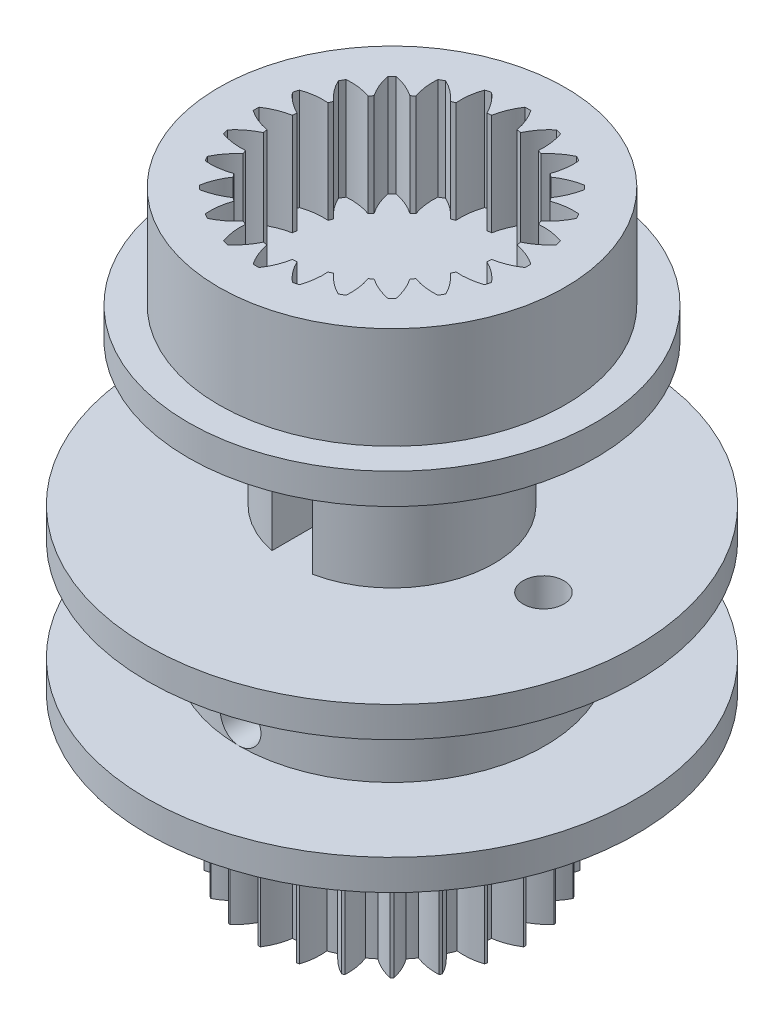
from build123d import *

# Parameters (mm, degrees)
BOSS_EXTRUDE1_DEPTH = 7.5
SKETCH2_R           = 12
BOSS_EXTRUDE2_DEPTH = 1.5
SKETCH3_R           = 7.5
BOSS_EXTRUDE3_DEPTH = 5
SKETCH4_R           = 12
BOSS_EXTRUDE4_DEPTH = 1.5
SKETCH6_R           = 5
BOSS_EXTRUDE5_DEPTH = 7
SKETCH9_R           = 10
BOSS_EXTRUDE6_DEPTH = 1.5
SKETCH11_R          = 8.5
BOSS_EXTRUDE7_DEPTH = 5
SKETCH7_R           = 1
SKETCH7_W           = 2
SKETCH7_H           = 7
CUT_EXTRUDE1_DEPTH  = 25.02148298
SKETCH13_R          = 1
CUT_EXTRUDE2_DEPTH  = 4


with BuildPart() as part:
    # Sketch1 → Boss-Extrude1 (new body)
    with BuildSketch(Plane(origin=(0, 0, 0), x_dir=(1, 0, 0), z_dir=(0, 1, 0))):
        with BuildLine():
            ThreePointArc((17.643526795, -5.495767992), (17.367772644, -6.046845758), (17.21467944, -6.643745688))
            ThreePointArc((17.21467944, -6.643745688), (16.99967637, -6.667680728), (16.785804508, -6.700208145))
            ThreePointArc((16.785804508, -6.700208145), (16.483438759, -6.163270523), (16.074451282, -5.702340703))
            ThreePointArc((16.074451282, -5.702340703), (16.01546472, -5.717851037), (15.956625692, -5.733911974))
            ThreePointArc((15.956625692, -5.733911974), (15.832897056, -6.337582647), (15.839509448, -6.953767142))
            ThreePointArc((15.839509448, -6.953767142), (15.638027273, -7.032533504), (15.439861633, -7.119306687))
            ThreePointArc((15.439861633, -7.119306687), (15.008829064, -6.678922785), (14.494480081, -6.339552516))
            ThreePointArc((14.494480081, -6.339552516), (14.441517808, -6.369801195), (14.388840548, -6.400543529))
            ThreePointArc((14.388840548, -6.400543529), (14.42556933, -7.01566795), (14.591436692, -7.609145055))
            ThreePointArc((14.591436692, -7.609145055), (14.417206092, -7.737374942), (14.248251334, -7.872480442))
            ThreePointArc((14.248251334, -7.872480442), (13.717926103, -7.558661696), (13.133267648, -7.363978501))
            ThreePointArc((13.133267648, -7.363978501), (13.089938954, -7.406904126), (13.047013329, -7.450232819))
            ThreePointArc((13.047013329, -7.450232819), (13.241696524, -8.034891275), (13.555515271, -8.565216505))
            ThreePointArc((13.555515271, -8.565216505), (13.420409771, -8.734171263), (13.292179883, -8.908401864))
            ThreePointArc((13.292179883, -8.908401864), (12.698702778, -8.742534502), (12.083578358, -8.705805719))
            ThreePointArc((12.083578358, -8.705805719), (12.052836023, -8.75848298), (12.022587345, -8.811445253))
            ThreePointArc((12.022587345, -8.811445253), (12.361957614, -9.325794236), (12.802341515, -9.756826804))
            ThreePointArc((12.802341515, -9.756826804), (12.715568333, -9.954992445), (12.63680197, -10.156474619))
            ThreePointArc((12.63680197, -10.156474619), (12.020617475, -10.149862228), (11.416946803, -10.273590863))
            ThreePointArc((11.416946803, -10.273590863), (11.400885866, -10.332429891), (11.385375531, -10.391416453))
            ThreePointArc((11.385375531, -10.391416453), (11.846305351, -10.80040393), (12.383242973, -11.102769679))
            ThreePointArc((12.383242973, -11.102769679), (12.350715557, -11.316641542), (12.326780517, -11.531644612))
            ThreePointArc((12.326780517, -11.531644612), (11.729880587, -11.684737815), (11.178802821, -11.960491966))
            ThreePointArc((11.178802821, -11.960491966), (11.178517808, -12.02148298), (11.178802821, -12.082473993))
            ThreePointArc((11.178802821, -12.082473993), (11.729880587, -12.358228144), (12.326780517, -12.511321347))
            ThreePointArc((12.326780517, -12.511321347), (12.350715557, -12.726324418), (12.383242973, -12.94019628))
            ThreePointArc((12.383242973, -12.94019628), (11.846305351, -13.242562029), (11.385375531, -13.651549506))
            ThreePointArc((11.385375531, -13.651549506), (11.400885866, -13.710536068), (11.416946803, -13.769375096))
            ThreePointArc((11.416946803, -13.769375096), (12.020617475, -13.893103732), (12.63680197, -13.88649134))
            ThreePointArc((12.63680197, -13.88649134), (12.715568333, -14.087973515), (12.802341515, -14.286139155))
            ThreePointArc((12.802341515, -14.286139155), (12.361957614, -14.717171723), (12.022587345, -15.231520706))
            ThreePointArc((12.022587345, -15.231520706), (12.052836023, -15.28448298), (12.083578358, -15.33716024))
            ThreePointArc((12.083578358, -15.33716024), (12.698702778, -15.300431458), (13.292179883, -15.134564096))
            ThreePointArc((13.292179883, -15.134564096), (13.420409771, -15.308794696), (13.555515271, -15.477749454))
            ThreePointArc((13.555515271, -15.477749454), (13.241696524, -16.008074685), (13.047013329, -16.59273314))
            ThreePointArc((13.047013329, -16.59273314), (13.089938954, -16.636061834), (13.133267648, -16.678987459))
            ThreePointArc((13.133267648, -16.678987459), (13.717926103, -16.484304264), (14.248251334, -16.170485517))
            ThreePointArc((14.248251334, -16.170485517), (14.417206092, -16.305591017), (14.591436692, -16.433820905))
            ThreePointArc((14.591436692, -16.433820905), (14.42556933, -17.02729801), (14.388840548, -17.64242243))
            ThreePointArc((14.388840548, -17.64242243), (14.441517808, -17.673164765), (14.494480081, -17.703413443))
            ThreePointArc((14.494480081, -17.703413443), (15.008829064, -17.364043174), (15.439861633, -16.923659273))
            ThreePointArc((15.439861633, -16.923659273), (15.638027273, -17.010432455), (15.839509448, -17.089198818))
            ThreePointArc((15.839509448, -17.089198818), (15.832897056, -17.705383313), (15.956625692, -18.309053985))
            ThreePointArc((15.956625692, -18.309053985), (16.01546472, -18.325114922), (16.074451282, -18.340625257))
            ThreePointArc((16.074451282, -18.340625257), (16.483438759, -17.879695437), (16.785804508, -17.342757815))
            ThreePointArc((16.785804508, -17.342757815), (16.99967637, -17.375285231), (17.21467944, -17.399220271))
            ThreePointArc((17.21467944, -17.399220271), (17.367772644, -17.996120201), (17.643526795, -18.547197967))
            ThreePointArc((17.643526795, -18.547197967), (17.704517808, -18.54748298), (17.765508822, -18.547197967))
            ThreePointArc((17.765508822, -18.547197967), (18.041262973, -17.996120201), (18.194356176, -17.399220271))
            ThreePointArc((18.194356176, -17.399220271), (18.409359246, -17.375285231), (18.623231109, -17.342757815))
            ThreePointArc((18.623231109, -17.342757815), (18.925596857, -17.879695437), (19.334584335, -18.340625257))
            ThreePointArc((19.334584335, -18.340625257), (19.393570897, -18.325114922), (19.452409925, -18.309053985))
            ThreePointArc((19.452409925, -18.309053985), (19.57613856, -17.705383313), (19.569526169, -17.089198818))
            ThreePointArc((19.569526169, -17.089198818), (19.771008343, -17.010432455), (19.969173984, -16.923659273))
            ThreePointArc((19.969173984, -16.923659273), (20.400206552, -17.364043174), (20.914555535, -17.703413443))
            ThreePointArc((20.914555535, -17.703413443), (20.967517808, -17.673164765), (21.020195069, -17.64242243))
            ThreePointArc((21.020195069, -17.64242243), (20.983466286, -17.02729801), (20.817598924, -16.433820905))
            ThreePointArc((20.817598924, -16.433820905), (20.991829525, -16.305591017), (21.160784283, -16.170485517))
            ThreePointArc((21.160784283, -16.170485517), (21.691109513, -16.484304264), (22.275767969, -16.678987459))
            ThreePointArc((22.275767969, -16.678987459), (22.319096662, -16.636061834), (22.362022287, -16.59273314))
            ThreePointArc((22.362022287, -16.59273314), (22.167339092, -16.008074685), (21.853520346, -15.477749454))
            ThreePointArc((21.853520346, -15.477749454), (21.988625846, -15.308794696), (22.116855733, -15.134564096))
            ThreePointArc((22.116855733, -15.134564096), (22.710332838, -15.300431458), (23.325457258, -15.33716024))
            ThreePointArc((23.325457258, -15.33716024), (23.356199593, -15.28448298), (23.386448272, -15.231520706))
            ThreePointArc((23.386448272, -15.231520706), (23.047078003, -14.717171723), (22.606694101, -14.286139155))
            ThreePointArc((22.606694101, -14.286139155), (22.693467284, -14.087973515), (22.772233646, -13.88649134))
            ThreePointArc((22.772233646, -13.88649134), (23.388418141, -13.893103732), (23.992088814, -13.769375096))
            ThreePointArc((23.992088814, -13.769375096), (24.008149751, -13.710536068), (24.023660085, -13.651549506))
            ThreePointArc((24.023660085, -13.651549506), (23.562730265, -13.242562029), (23.025792643, -12.94019628))
            ThreePointArc((23.025792643, -12.94019628), (23.05832006, -12.726324418), (23.082255099, -12.511321347))
            ThreePointArc((23.082255099, -12.511321347), (23.67915503, -12.358228144), (24.230232796, -12.082473993))
            ThreePointArc((24.230232796, -12.082473993), (24.230517808, -12.02148298), (24.230232796, -11.960491966))
            ThreePointArc((24.230232796, -11.960491966), (23.67915503, -11.684737815), (23.082255099, -11.531644612))
            ThreePointArc((23.082255099, -11.531644612), (23.05832006, -11.316641542), (23.025792643, -11.102769679))
            ThreePointArc((23.025792643, -11.102769679), (23.562730265, -10.80040393), (24.023660085, -10.391416453))
            ThreePointArc((24.023660085, -10.391416453), (24.008149751, -10.332429891), (23.992088814, -10.273590863))
            ThreePointArc((23.992088814, -10.273590863), (23.388418141, -10.149862228), (22.772233646, -10.156474619))
            ThreePointArc((22.772233646, -10.156474619), (22.693467284, -9.954992445), (22.606694101, -9.756826804))
            ThreePointArc((22.606694101, -9.756826804), (23.047078003, -9.325794236), (23.386448272, -8.811445253))
            ThreePointArc((23.386448272, -8.811445253), (23.356199593, -8.75848298), (23.325457258, -8.705805719))
            ThreePointArc((23.325457258, -8.705805719), (22.710332838, -8.742534502), (22.116855733, -8.908401864))
            ThreePointArc((22.116855733, -8.908401864), (21.988625846, -8.734171263), (21.853520346, -8.565216505))
            ThreePointArc((21.853520346, -8.565216505), (22.167339092, -8.034891275), (22.362022287, -7.450232819))
            ThreePointArc((22.362022287, -7.450232819), (22.319096662, -7.406904126), (22.275767969, -7.363978501))
            ThreePointArc((22.275767969, -7.363978501), (21.691109513, -7.558661696), (21.160784283, -7.872480442))
            ThreePointArc((21.160784283, -7.872480442), (20.991829525, -7.737374942), (20.817598924, -7.609145055))
            ThreePointArc((20.817598924, -7.609145055), (20.983466286, -7.01566795), (21.020195069, -6.400543529))
            ThreePointArc((21.020195069, -6.400543529), (20.967517808, -6.369801195), (20.914555535, -6.339552516))
            ThreePointArc((20.914555535, -6.339552516), (20.400206552, -6.678922785), (19.969173984, -7.119306687))
            ThreePointArc((19.969173984, -7.119306687), (19.771008343, -7.032533504), (19.569526169, -6.953767142))
            ThreePointArc((19.569526169, -6.953767142), (19.57613856, -6.337582647), (19.452409925, -5.733911974))
            ThreePointArc((19.452409925, -5.733911974), (19.393570897, -5.717851037), (19.334584335, -5.702340703))
            ThreePointArc((19.334584335, -5.702340703), (18.925596857, -6.163270523), (18.623231109, -6.700208145))
            ThreePointArc((18.623231109, -6.700208145), (18.409359246, -6.667680728), (18.194356176, -6.643745688))
            ThreePointArc((18.194356176, -6.643745688), (18.041262973, -6.046845758), (17.765508822, -5.495767992))
            ThreePointArc((17.765508822, -5.495767992), (17.704517808, -5.49548298), (17.643526795, -5.495767992))
        make_face()
    extrude(amount=BOSS_EXTRUDE1_DEPTH)

    # Sketch2 → Boss-Extrude2 (add)
    with BuildSketch(Plane(origin=(0, 7.5, 0), x_dir=(1, 0, 0), z_dir=(0, 1, 0))):
        with Locations((17.704517808, -12.02148298)):
            Circle(SKETCH2_R)
    extrude(amount=BOSS_EXTRUDE2_DEPTH)

    # Sketch3 → Boss-Extrude3 (add)
    with BuildSketch(Plane(origin=(0, 9, 0), x_dir=(1, 0, 0), z_dir=(0, 1, 0))):
        with Locations((17.704517808, -12.02148298)):
            Circle(SKETCH3_R)
    extrude(amount=BOSS_EXTRUDE3_DEPTH)

    # Sketch4 → Boss-Extrude4 (add)
    with BuildSketch(Plane(origin=(0, 14, 0), x_dir=(1, 0, 0), z_dir=(0, 1, 0))):
        with Locations((17.704517808, -12.02148298)):
            Circle(SKETCH4_R)
    extrude(amount=BOSS_EXTRUDE4_DEPTH)

    # Sketch6 → Boss-Extrude5 (add)
    with BuildSketch(Plane(origin=(0, 15.5, 0), x_dir=(1, 0, 0), z_dir=(0, 1, 0))):
        with Locations((17.704517808, -12.02148298)):
            Circle(SKETCH6_R)
    extrude(amount=BOSS_EXTRUDE5_DEPTH)

    # Sketch9 → Boss-Extrude6 (add)
    with BuildSketch(Plane(origin=(0, 22.5, 0), x_dir=(1, 0, 0), z_dir=(0, 1, 0))):
        with Locations((17.704517808, -12.02148298)):
            Circle(SKETCH9_R)
    extrude(amount=BOSS_EXTRUDE6_DEPTH)

    # Sketch11 → Boss-Extrude7 (add)
    with BuildSketch(Plane(origin=(0, 24, 0), x_dir=(1, 0, 0), z_dir=(0, 1, 0))):
        with Locations((17.704517808, -12.02148298)):
            Circle(SKETCH11_R)
        with BuildLine():
            ThreePointArc((17.847000215, -5.347003617), (17.704517808, -5.34548298), (17.562035401, -5.347003617))
            ThreePointArc((17.562035401, -5.347003617), (17.263554819, -5.901817538), (17.085431236, -6.506119726))
            ThreePointArc((17.085431236, -6.506119726), (16.980097441, -6.518963999), (16.875028466, -6.533819777))
            ThreePointArc((16.875028466, -6.533819777), (16.546569382, -5.996210462), (16.11466287, -5.537553826))
            ThreePointArc((16.11466287, -5.537553826), (15.976641863, -5.572962163), (15.839407996, -5.611308147))
            ThreePointArc((15.839407996, -5.611308147), (15.694694302, -6.224469701), (15.679045049, -6.854282567))
            ThreePointArc((15.679045049, -6.854282567), (15.580624759, -6.893951574), (15.48298088, -6.935495005))
            ThreePointArc((15.48298088, -6.935495005), (15.026570239, -6.50121575), (14.490671511, -6.169973091))
            ThreePointArc((14.490671511, -6.169973091), (14.366517808, -6.239897384), (14.243884743, -6.312455498))
            ThreePointArc((14.243884743, -6.312455498), (14.262799936, -6.94217874), (14.410691483, -7.554581577))
            ThreePointArc((14.410691483, -7.554581577), (14.325891877, -7.618371941), (14.242327365, -7.683771909))
            ThreePointArc((14.242327365, -7.683771909), (13.689068796, -7.382418127), (13.085698466, -7.201163085))
            ThreePointArc((13.085698466, -7.201163085), (12.983872937, -7.300838109), (12.884197914, -7.402663638))
            ThreePointArc((12.884197914, -7.402663638), (13.065452956, -8.006033968), (13.366806738, -8.559292536))
            ThreePointArc((13.366806738, -8.559292536), (13.30140677, -8.642857049), (13.237616406, -8.727656654))
            ThreePointArc((13.237616406, -8.727656654), (12.625213568, -8.579765108), (11.995490327, -8.560849914))
            ThreePointArc((11.995490327, -8.560849914), (11.922932213, -8.68348298), (11.85300792, -8.807636682))
            ThreePointArc((11.85300792, -8.807636682), (12.184250578, -9.34353541), (12.618529834, -9.799946052))
            ThreePointArc((12.618529834, -9.799946052), (12.576986403, -9.89758993), (12.537317396, -9.99601022))
            ThreePointArc((12.537317396, -9.99601022), (11.90750453, -10.011659474), (11.294342975, -10.156373168))
            ThreePointArc((11.294342975, -10.156373168), (11.255996992, -10.293607035), (11.220588654, -10.431628041))
            ThreePointArc((11.220588654, -10.431628041), (11.67924529, -10.863534554), (12.216854605, -11.191993638))
            ThreePointArc((12.216854605, -11.191993638), (12.201998828, -11.297062613), (12.189154555, -11.402396407))
            ThreePointArc((12.189154555, -11.402396407), (11.584852367, -11.58051999), (11.030038445, -11.879000573))
            ThreePointArc((11.030038445, -11.879000573), (11.028517808, -12.02148298), (11.030038445, -12.163965387))
            ThreePointArc((11.030038445, -12.163965387), (11.584852367, -12.462445969), (12.189154555, -12.640569552))
            ThreePointArc((12.189154555, -12.640569552), (12.201998828, -12.745903347), (12.216854605, -12.850972321))
            ThreePointArc((12.216854605, -12.850972321), (11.67924529, -13.179431406), (11.220588654, -13.611337918))
            ThreePointArc((11.220588654, -13.611337918), (11.255996992, -13.749358925), (11.294342975, -13.886592792))
            ThreePointArc((11.294342975, -13.886592792), (11.90750453, -14.031306486), (12.537317396, -14.046955739))
            ThreePointArc((12.537317396, -14.046955739), (12.576986403, -14.145376029), (12.618529834, -14.243019908))
            ThreePointArc((12.618529834, -14.243019908), (12.184250578, -14.699430549), (11.85300792, -15.235329277))
            ThreePointArc((11.85300792, -15.235329277), (11.922932213, -15.35948298), (11.995490327, -15.482116045))
            ThreePointArc((11.995490327, -15.482116045), (12.625213568, -15.463200852), (13.237616406, -15.315309305))
            ThreePointArc((13.237616406, -15.315309305), (13.30140677, -15.400108911), (13.366806738, -15.483673423))
            ThreePointArc((13.366806738, -15.483673423), (13.065452956, -16.036931992), (12.884197914, -16.640302322))
            ThreePointArc((12.884197914, -16.640302322), (12.983872937, -16.742127851), (13.085698466, -16.841802874))
            ThreePointArc((13.085698466, -16.841802874), (13.689068796, -16.660547832), (14.242327365, -16.35919405))
            ThreePointArc((14.242327365, -16.35919405), (14.325891877, -16.424594018), (14.410691483, -16.488384382))
            ThreePointArc((14.410691483, -16.488384382), (14.262799936, -17.10078722), (14.243884743, -17.730510461))
            ThreePointArc((14.243884743, -17.730510461), (14.366517808, -17.803068575), (14.490671511, -17.872992868))
            ThreePointArc((14.490671511, -17.872992868), (15.026570239, -17.54175021), (15.48298088, -17.107470954))
            ThreePointArc((15.48298088, -17.107470954), (15.580624759, -17.149014385), (15.679045049, -17.188683392))
            ThreePointArc((15.679045049, -17.188683392), (15.694694302, -17.818496258), (15.839407996, -18.431657813))
            ThreePointArc((15.839407996, -18.431657813), (15.976641863, -18.470003796), (16.11466287, -18.505412134))
            ThreePointArc((16.11466287, -18.505412134), (16.546569382, -18.046755498), (16.875028466, -17.509146183))
            ThreePointArc((16.875028466, -17.509146183), (16.980097441, -17.52400196), (17.085431236, -17.536846233))
            ThreePointArc((17.085431236, -17.536846233), (17.263554819, -18.141148421), (17.562035401, -18.695962342))
            ThreePointArc((17.562035401, -18.695962342), (17.704517808, -18.69748298), (17.847000215, -18.695962342))
            ThreePointArc((17.847000215, -18.695962342), (18.145480798, -18.141148421), (18.323604381, -17.536846233))
            ThreePointArc((18.323604381, -17.536846233), (18.428938175, -17.52400196), (18.53400715, -17.509146183))
            ThreePointArc((18.53400715, -17.509146183), (18.862466234, -18.046755498), (19.294372747, -18.505412134))
            ThreePointArc((19.294372747, -18.505412134), (19.432393753, -18.470003796), (19.56962762, -18.431657813))
            ThreePointArc((19.56962762, -18.431657813), (19.714341314, -17.818496258), (19.729990568, -17.188683392))
            ThreePointArc((19.729990568, -17.188683392), (19.828410858, -17.149014385), (19.926054736, -17.107470954))
            ThreePointArc((19.926054736, -17.107470954), (20.382465378, -17.54175021), (20.918364105, -17.872992868))
            ThreePointArc((20.918364105, -17.872992868), (21.042517808, -17.803068575), (21.165150874, -17.730510461))
            ThreePointArc((21.165150874, -17.730510461), (21.14623568, -17.10078722), (20.998344134, -16.488384382))
            ThreePointArc((20.998344134, -16.488384382), (21.083143739, -16.424594018), (21.166708252, -16.35919405))
            ThreePointArc((21.166708252, -16.35919405), (21.71996682, -16.660547832), (22.32333715, -16.841802874))
            ThreePointArc((22.32333715, -16.841802874), (22.425162679, -16.742127851), (22.524837703, -16.640302322))
            ThreePointArc((22.524837703, -16.640302322), (22.343582661, -16.036931992), (22.042228879, -15.483673423))
            ThreePointArc((22.042228879, -15.483673423), (22.107628847, -15.400108911), (22.171419211, -15.315309305))
            ThreePointArc((22.171419211, -15.315309305), (22.783822048, -15.463200852), (23.41354529, -15.482116045))
            ThreePointArc((23.41354529, -15.482116045), (23.486103404, -15.35948298), (23.556027697, -15.235329277))
            ThreePointArc((23.556027697, -15.235329277), (23.224785038, -14.699430549), (22.790505783, -14.243019908))
            ThreePointArc((22.790505783, -14.243019908), (22.832049214, -14.145376029), (22.87171822, -14.046955739))
            ThreePointArc((22.87171822, -14.046955739), (23.501531086, -14.031306486), (24.114692641, -13.886592792))
            ThreePointArc((24.114692641, -13.886592792), (24.153038625, -13.749358925), (24.188446962, -13.611337918))
            ThreePointArc((24.188446962, -13.611337918), (23.729790326, -13.179431406), (23.192181011, -12.850972321))
            ThreePointArc((23.192181011, -12.850972321), (23.207036789, -12.745903347), (23.219881062, -12.640569552))
            ThreePointArc((23.219881062, -12.640569552), (23.82418325, -12.462445969), (24.378997171, -12.163965387))
            ThreePointArc((24.378997171, -12.163965387), (24.380517808, -12.02148298), (24.378997171, -11.879000573))
            ThreePointArc((24.378997171, -11.879000573), (23.82418325, -11.58051999), (23.219881062, -11.402396407))
            ThreePointArc((23.219881062, -11.402396407), (23.207036789, -11.297062613), (23.192181011, -11.191993638))
            ThreePointArc((23.192181011, -11.191993638), (23.729790326, -10.863534554), (24.188446962, -10.431628041))
            ThreePointArc((24.188446962, -10.431628041), (24.153038625, -10.293607035), (24.114692641, -10.156373168))
            ThreePointArc((24.114692641, -10.156373168), (23.501531086, -10.011659474), (22.87171822, -9.99601022))
            ThreePointArc((22.87171822, -9.99601022), (22.832049214, -9.89758993), (22.790505783, -9.799946052))
            ThreePointArc((22.790505783, -9.799946052), (23.224785038, -9.34353541), (23.556027697, -8.807636682))
            ThreePointArc((23.556027697, -8.807636682), (23.486103404, -8.68348298), (23.41354529, -8.560849914))
            ThreePointArc((23.41354529, -8.560849914), (22.783822048, -8.579765108), (22.171419211, -8.727656654))
            ThreePointArc((22.171419211, -8.727656654), (22.107628847, -8.642857049), (22.042228879, -8.559292536))
            ThreePointArc((22.042228879, -8.559292536), (22.343582661, -8.006033968), (22.524837703, -7.402663638))
            ThreePointArc((22.524837703, -7.402663638), (22.425162679, -7.300838109), (22.32333715, -7.201163085))
            ThreePointArc((22.32333715, -7.201163085), (21.71996682, -7.382418127), (21.166708252, -7.683771909))
            ThreePointArc((21.166708252, -7.683771909), (21.083143739, -7.618371941), (20.998344134, -7.554581577))
            ThreePointArc((20.998344134, -7.554581577), (21.14623568, -6.94217874), (21.165150874, -6.312455498))
            ThreePointArc((21.165150874, -6.312455498), (21.042517808, -6.239897384), (20.918364105, -6.169973091))
            ThreePointArc((20.918364105, -6.169973091), (20.382465378, -6.50121575), (19.926054736, -6.935495005))
            ThreePointArc((19.926054736, -6.935495005), (19.828410858, -6.893951574), (19.729990568, -6.854282567))
            ThreePointArc((19.729990568, -6.854282567), (19.714341314, -6.224469701), (19.56962762, -5.611308147))
            ThreePointArc((19.56962762, -5.611308147), (19.432393753, -5.572962163), (19.294372747, -5.537553826))
            ThreePointArc((19.294372747, -5.537553826), (18.862466234, -5.996210462), (18.53400715, -6.533819777))
            ThreePointArc((18.53400715, -6.533819777), (18.428938175, -6.518963999), (18.323604381, -6.506119726))
            ThreePointArc((18.323604381, -6.506119726), (18.145480798, -5.901817538), (17.847000215, -5.347003617))
        make_face(mode=Mode.SUBTRACT)
    extrude(amount=BOSS_EXTRUDE7_DEPTH)

    # Sketch7 → Cut-Extrude1 (cut, through all)
    with BuildSketch(Plane.XY):
        with Locations((17.704517808, 10)):
            Circle(SKETCH7_R)
        with Locations((17.704517808, 19)):
            Rectangle(SKETCH7_W, SKETCH7_H)
    extrude(amount=CUT_EXTRUDE1_DEPTH, mode=Mode.SUBTRACT)

    # Sketch13 → Cut-Extrude2 (cut)
    with BuildSketch(Plane(origin=(0, 14, 0), x_dir=(1, 0, 0), z_dir=(0, 1, 0))):
        with Locations((25.141507602, -12.02148298)):
            Circle(SKETCH13_R)
    extrude(amount=CUT_EXTRUDE2_DEPTH, mode=Mode.SUBTRACT)


solid = part.part
